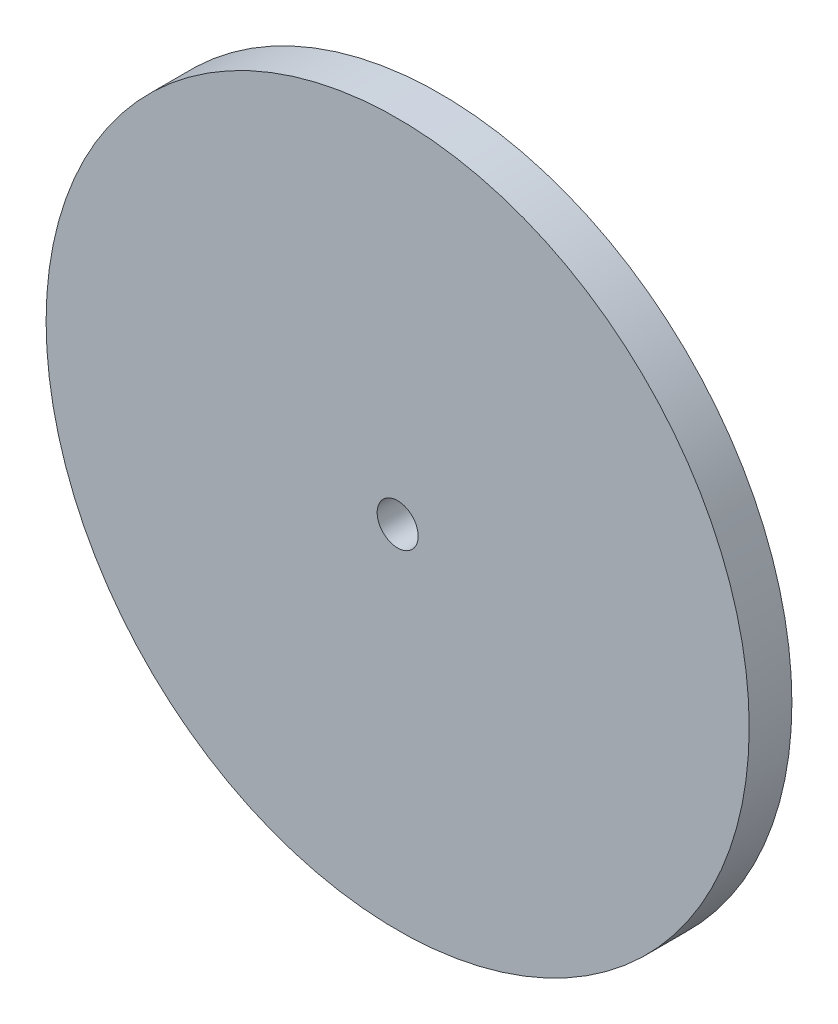
from build123d import *

# Parameters (mm, degrees)
SKETCH1_R           = 41.162278462
SKETCH1_R_2         = 2.4
BOSS_EXTRUDE1_DEPTH = 5


with BuildPart() as part:
    # Sketch1 → Boss-Extrude1 (new body)
    with BuildSketch(Plane.XY):
        Circle(SKETCH1_R)
        Circle(SKETCH1_R_2, mode=Mode.SUBTRACT)
    extrude(amount=BOSS_EXTRUDE1_DEPTH)


solid = part.part
